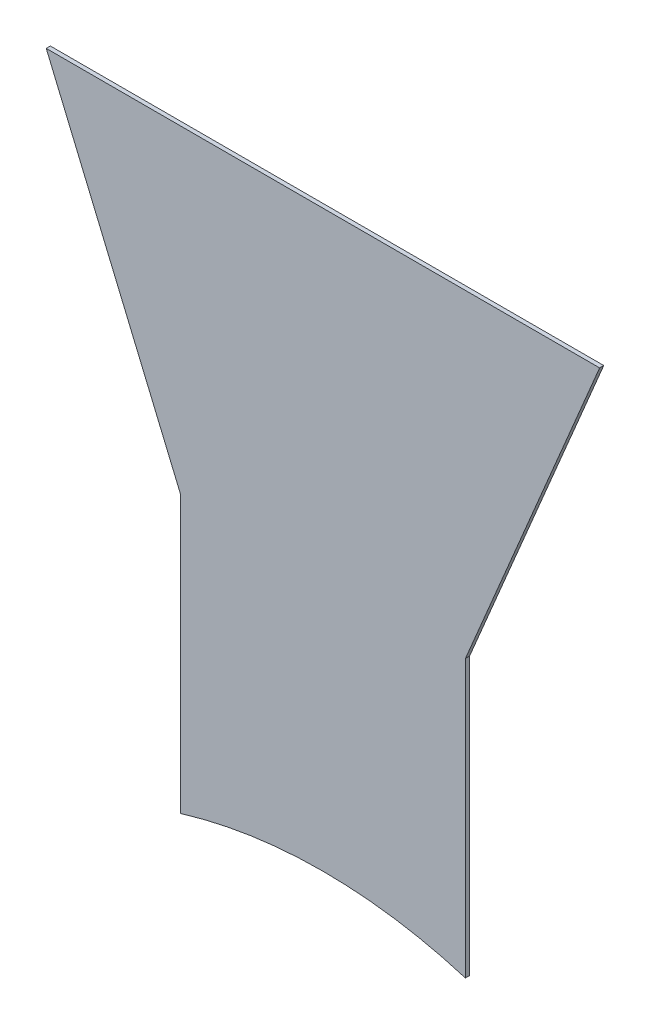
from build123d import *

# Parameters (mm, degrees)
BOSS_EXTRUDE1_DEPTH = 1.51892


with BuildPart() as part:
    # Sketch1 → Boss-Extrude1 (new body)
    with BuildSketch(Plane.XY):
        with BuildLine():
            Line((-52.31892, 171.516779587), (-52.31892, 273.116779587))
            Line((-52.31892, 273.116779587), (-101.6, 390.165381262))
            Line((-101.6, 390.165381262), (101.6, 390.165381262))
            Line((101.6, 390.165381262), (52.31892, 273.116779587))
            Line((52.31892, 273.116779587), (52.31892, 171.516779587))
            ThreePointArc((52.31892, 171.516779587), (0, 179.31892), (-52.31892, 171.516779587))
        make_face()
    extrude(amount=BOSS_EXTRUDE1_DEPTH)


solid = part.part
